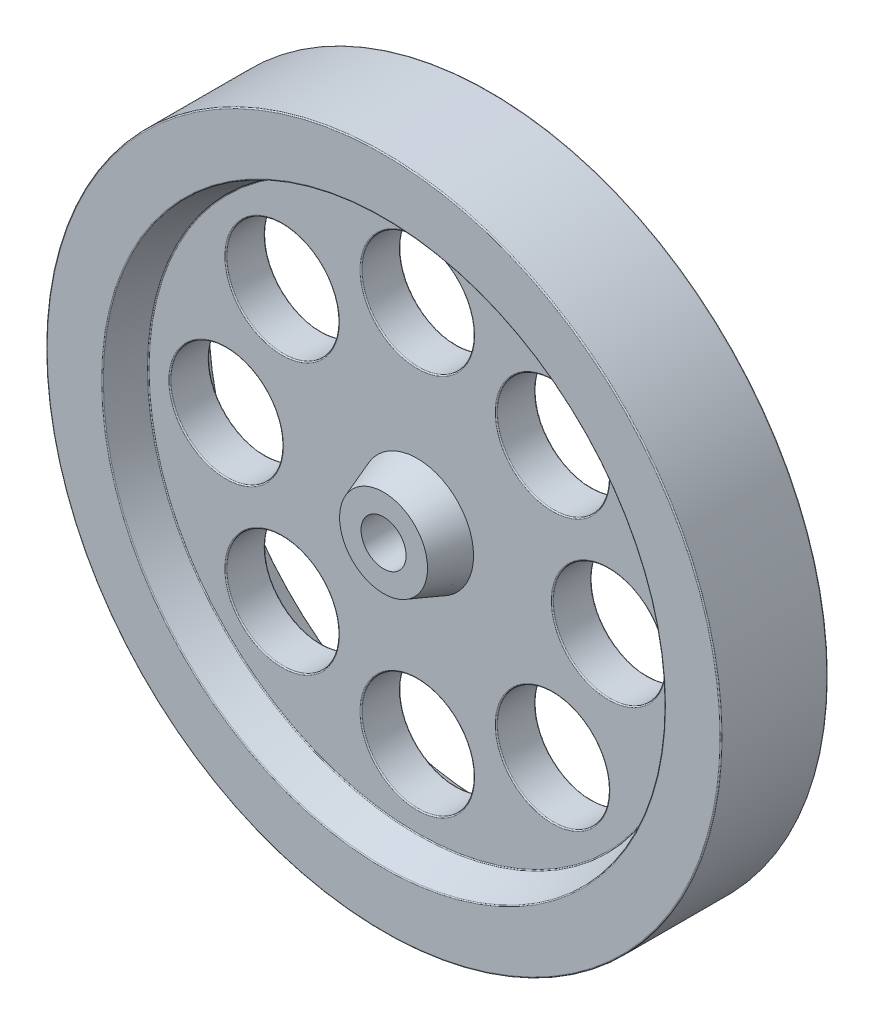
from build123d import *

# Parameters (mm, degrees)
SKETCH3_R           = 30
BOSS_EXTRUDE2_DEPTH = 4.75
SKETCH4_R           = 25
CUT_EXTRUDE1_DEPTH  = 3
CUT_EXTRUDE1_TAPER  = 20
CUT_EXTRUDE2_REACH  = 8.5
SKETCH5_R           = 5
FILLET1_R           = 0.1
SKETCH8_R           = 5
BOSS_EXTRUDE4_DEPTH = 3
BOSS_EXTRUDE4_TAPER = 20
SKETCH9_R           = 5
BOSS_EXTRUDE5_DEPTH = 3
BOSS_EXTRUDE5_TAPER = 20


with BuildPart() as part:
    # Sketch3 → Boss-Extrude2 (new body, symmetric)
    with BuildSketch(Plane.XY):
        Circle(SKETCH3_R)
    extrude(amount=BOSS_EXTRUDE2_DEPTH, both=True)

    # Sketch4 → Cut-Extrude1 (cut)
    with BuildSketch(Plane.XY.offset(4.75)):
        Circle(SKETCH4_R)
    cut_extrude1 = extrude(amount=-CUT_EXTRUDE1_DEPTH, taper=CUT_EXTRUDE1_TAPER, mode=Mode.SUBTRACT)

    # Mirror1: Cut-Extrude1 across plane
    add(cut_extrude1.mirror(Plane.XY), mode=Mode.SUBTRACT)

    # Sketch5 → Cut-Extrude2 (cut, up to next)
    with BuildSketch(Plane.XY.offset(1.75), mode=Mode.PRIVATE) as cut_extrude2_sk1:
        with Locations((0, 17)):
            Circle(SKETCH5_R)
    cut_extrude2_tool1 = extrude(cut_extrude2_sk1.sketch, amount=-CUT_EXTRUDE2_REACH, mode=Mode.PRIVATE) & part.part
    add(cut_extrude2_tool1.solids().sort_by_distance((0, 17, 1.75))[0], mode=Mode.SUBTRACT)
    # Sketch5 → Cut-Extrude2 (cut, up to next)
    with BuildSketch(Plane.XY.offset(1.75), mode=Mode.PRIVATE) as cut_extrude2_sk2:
        with Locations((12.02081528, 12.02081528)):
            Circle(SKETCH5_R)
    cut_extrude2_tool2 = extrude(cut_extrude2_sk2.sketch, amount=-CUT_EXTRUDE2_REACH, mode=Mode.PRIVATE) & part.part
    add(cut_extrude2_tool2.solids().sort_by_distance((12.020815, 12.020815, 1.75))[0], mode=Mode.SUBTRACT)
    # Sketch5 → Cut-Extrude2 (cut, up to next)
    with BuildSketch(Plane.XY.offset(1.75), mode=Mode.PRIVATE) as cut_extrude2_sk3:
        with Locations((17, 0)):
            Circle(SKETCH5_R)
    cut_extrude2_tool3 = extrude(cut_extrude2_sk3.sketch, amount=-CUT_EXTRUDE2_REACH, mode=Mode.PRIVATE) & part.part
    add(cut_extrude2_tool3.solids().sort_by_distance((17, 0, 1.75))[0], mode=Mode.SUBTRACT)
    # Sketch5 → Cut-Extrude2 (cut, up to next)
    with BuildSketch(Plane.XY.offset(1.75), mode=Mode.PRIVATE) as cut_extrude2_sk4:
        with Locations((12.02081528, -12.02081528)):
            Circle(SKETCH5_R)
    cut_extrude2_tool4 = extrude(cut_extrude2_sk4.sketch, amount=-CUT_EXTRUDE2_REACH, mode=Mode.PRIVATE) & part.part
    add(cut_extrude2_tool4.solids().sort_by_distance((12.020815, -12.020815, 1.75))[0], mode=Mode.SUBTRACT)
    # Sketch5 → Cut-Extrude2 (cut, up to next)
    with BuildSketch(Plane.XY.offset(1.75), mode=Mode.PRIVATE) as cut_extrude2_sk5:
        with Locations((0, -17)):
            Circle(SKETCH5_R)
    cut_extrude2_tool5 = extrude(cut_extrude2_sk5.sketch, amount=-CUT_EXTRUDE2_REACH, mode=Mode.PRIVATE) & part.part
    add(cut_extrude2_tool5.solids().sort_by_distance((0, -17, 1.75))[0], mode=Mode.SUBTRACT)
    # Sketch5 → Cut-Extrude2 (cut, up to next)
    with BuildSketch(Plane.XY.offset(1.75), mode=Mode.PRIVATE) as cut_extrude2_sk6:
        with Locations((-12.02081528, -12.02081528)):
            Circle(SKETCH5_R)
    cut_extrude2_tool6 = extrude(cut_extrude2_sk6.sketch, amount=-CUT_EXTRUDE2_REACH, mode=Mode.PRIVATE) & part.part
    add(cut_extrude2_tool6.solids().sort_by_distance((-12.020815, -12.020815, 1.75))[0], mode=Mode.SUBTRACT)
    # Sketch5 → Cut-Extrude2 (cut, up to next)
    with BuildSketch(Plane.XY.offset(1.75), mode=Mode.PRIVATE) as cut_extrude2_sk7:
        with Locations((-17, 0)):
            Circle(SKETCH5_R)
    cut_extrude2_tool7 = extrude(cut_extrude2_sk7.sketch, amount=-CUT_EXTRUDE2_REACH, mode=Mode.PRIVATE) & part.part
    add(cut_extrude2_tool7.solids().sort_by_distance((-17, 0, 1.75))[0], mode=Mode.SUBTRACT)
    # Sketch5 → Cut-Extrude2 (cut, up to next)
    with BuildSketch(Plane.XY.offset(1.75), mode=Mode.PRIVATE) as cut_extrude2_sk8:
        with Locations((-12.02081528, 12.02081528)):
            Circle(SKETCH5_R)
    cut_extrude2_tool8 = extrude(cut_extrude2_sk8.sketch, amount=-CUT_EXTRUDE2_REACH, mode=Mode.PRIVATE) & part.part
    add(cut_extrude2_tool8.solids().sort_by_distance((-12.020815, 12.020815, 1.75))[0], mode=Mode.SUBTRACT)

    # Fillet1
    fillet1_edges = [part.edges().sort_by_distance(p)[0] for p in [
        (-25, 0, -4.75),
        (-23.908089297, 0, -1.75),
        (-30, 0, -4.75),
        (-17.02081528, 12.02081528, -1.75),
        (-17.02081528, 12.02081528, 1.75),
        (-22, 0, -1.75),
        (-22, 0, 1.75),
        (-17.02081528, -12.02081528, -1.75),
        (-17.02081528, -12.02081528, 1.75),
        (-5, -17, -1.75),
        (-5, -17, 1.75),
        (7.02081528, -12.02081528, -1.75),
        (7.02081528, -12.02081528, 1.75),
        (12, 0, -1.75),
        (12, 0, 1.75),
        (7.02081528, 12.02081528, -1.75),
        (7.02081528, 12.02081528, 1.75),
        (-5, 17, -1.75),
        (-5, 17, 1.75),
        (-30, 0, 4.75),
        (-23.908089297, 0, 1.75),
        (-25, 0, 4.75),
    ]]
    fillet(fillet1_edges, radius=FILLET1_R)

    # Sketch8 → Boss-Extrude4 (add)
    with BuildSketch(Plane.XY.offset(1.75)):
        Circle(SKETCH8_R)
    extrude(amount=BOSS_EXTRUDE4_DEPTH, taper=BOSS_EXTRUDE4_TAPER)

    # Sketch9 → Boss-Extrude5 (add)
    with BuildSketch(Plane(origin=(0, 0, -1.75), x_dir=(-1, 0, 0), z_dir=(0, 0, -1))):
        Circle(SKETCH9_R)
    extrude(amount=BOSS_EXTRUDE5_DEPTH, taper=BOSS_EXTRUDE5_TAPER)

    # Sketch10 → Cut-Revolve1 (revolve, cut)
    with BuildSketch(Plane(origin=(0, 0, 0), x_dir=(0, 0, -1), z_dir=(1, 0, 0))):
        Polygon((-4.75, 2), (1.25, 2), (1.25, 1.5), (3.75, 1.5), (4.75, 2.5), (4.75, 0), (-4.75, 0), align=None)
    revolve(axis=Axis((0, 0, -4.75), (0, 0, 1)), mode=Mode.SUBTRACT)


solid = part.part
